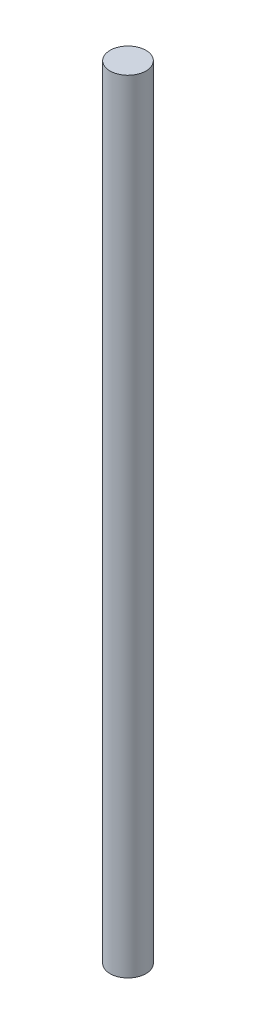
from build123d import *

# Parameters (mm, degrees)
SKETCH1_R           = 2.5
BOSS_EXTRUDE1_DEPTH = 109


with BuildPart() as part:
    # Sketch1 → Boss-Extrude1 (new body)
    with BuildSketch(Plane(origin=(0, 0, 0), x_dir=(1, 0, 0), z_dir=(0, 1, 0))):
        Circle(SKETCH1_R)
    extrude(amount=BOSS_EXTRUDE1_DEPTH)


solid = part.part
